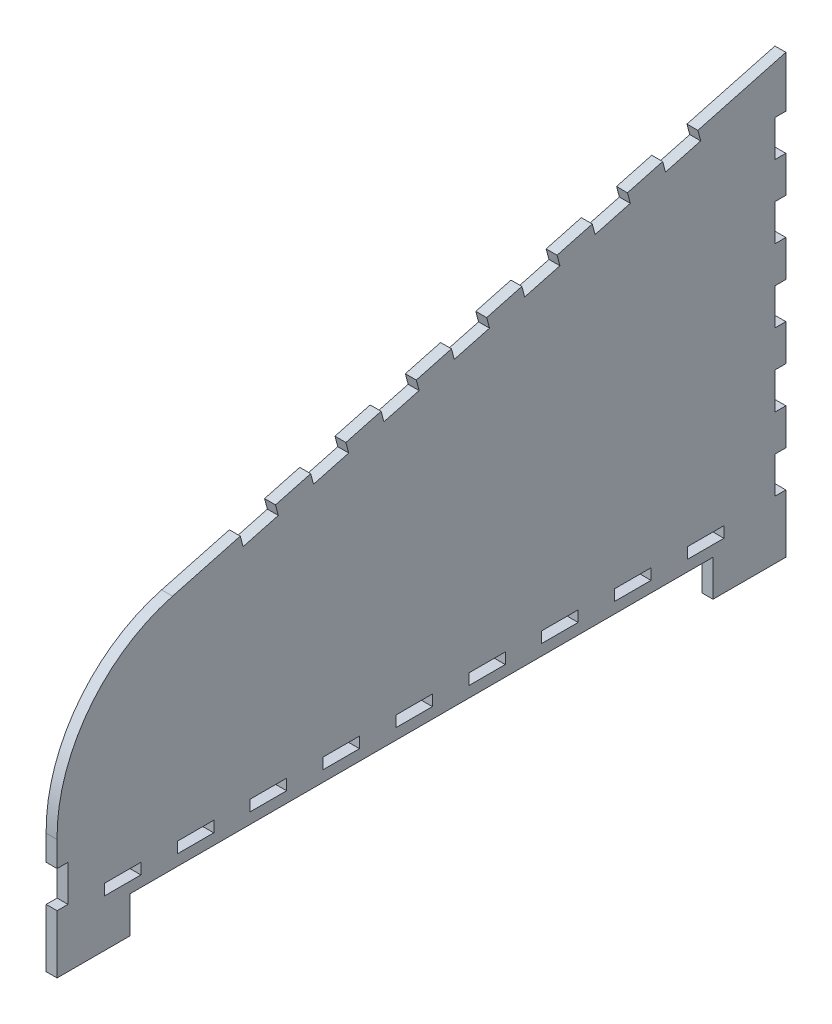
from build123d import *

# Parameters (mm, degrees)
SKETCH1_W           = 10
SKETCH1_H           = 3
BOSS_EXTRUDE1_DEPTH = 3


with BuildPart() as part:
    # Sketch1 → Boss-Extrude1 (new body)
    with BuildSketch(Plane(origin=(0, 0, 0), x_dir=(0, 0, -1), z_dir=(1, 0, 0))):
        with BuildLine():
            Line((-100, -44), (-100, -60))
            Line((-100, -60), (-80, -60))
            Line((-80, -60), (-80, -50))
            Line((-80, -50), (80, -50))
            Line((80, -50), (80, -60))
            Line((80, -60), (100, -60))
            Line((100, -60), (100, -44))
            Line((100, -44), (97, -44))
            Line((97, -44), (97, -34))
            Line((97, -34), (100, -34))
            Line((100, -34), (100, -24))
            Line((100, -24), (97, -24))
            Line((97, -24), (97, -14))
            Line((97, -14), (100, -14))
            Line((100, -14), (100, -4))
            Line((100, -4), (97, -4))
            Line((97, -4), (97, 6))
            Line((97, 6), (100, 6))
            Line((100, 6), (100, 16))
            Line((100, 16), (97, 16))
            Line((97, 16), (97, 26))
            Line((97, 26), (100, 26))
            Line((100, 26), (100, 36))
            Line((100, 36), (97, 36))
            Line((97, 36), (97, 46))
            Line((97, 46), (100, 46))
            Line((100, 46), (100, 60))
            Line((100, 60), (75.851854343, 53.529523872))
            Line((75.851854343, 53.529523872), (76.628311478, 50.631746394))
            Line((76.628311478, 50.631746394), (66.969053215, 48.043555943))
            Line((66.969053215, 48.043555943), (66.19259608, 50.941333421))
            Line((66.19259608, 50.941333421), (56.533337817, 48.35314297))
            Line((56.533337817, 48.35314297), (57.309794952, 45.455365492))
            Line((57.309794952, 45.455365492), (47.650536689, 42.86717504))
            Line((47.650536689, 42.86717504), (46.874079554, 45.764952519))
            Line((46.874079554, 45.764952519), (37.214821291, 43.176762068))
            Line((37.214821291, 43.176762068), (37.991278427, 40.278984589))
            Line((37.991278427, 40.278984589), (28.332020164, 37.690794138))
            Line((28.332020164, 37.690794138), (27.555563028, 40.588571617))
            Line((27.555563028, 40.588571617), (17.896304765, 38.000381166))
            Line((17.896304765, 38.000381166), (18.672761901, 35.102603687))
            Line((18.672761901, 35.102603687), (9.013503638, 32.514413236))
            Line((9.013503638, 32.514413236), (8.237046503, 35.412190715))
            Line((8.237046503, 35.412190715), (-1.42221176, 32.824000264))
            Line((-1.42221176, 32.824000264), (-0.645754625, 29.926222785))
            Line((-0.645754625, 29.926222785), (-10.305012888, 27.338032334))
            Line((-10.305012888, 27.338032334), (-11.081470023, 30.235809813))
            Line((-11.081470023, 30.235809813), (-20.740728286, 27.647619362))
            Line((-20.740728286, 27.647619362), (-19.964271151, 24.749841883))
            Line((-19.964271151, 24.749841883), (-29.623529414, 22.161651432))
            Line((-29.623529414, 22.161651432), (-30.399986549, 25.059428911))
            Line((-30.399986549, 25.059428911), (-40.059244812, 22.47123846))
            Line((-40.059244812, 22.47123846), (-39.282787677, 19.573460981))
            Line((-39.282787677, 19.573460981), (-48.942045939, 16.98527053))
            Line((-48.942045939, 16.98527053), (-49.718503075, 19.883048009))
            Line((-49.718503075, 19.883048009), (-68.302221487, 14.903555668))
            ThreePointArc((-68.302221487, 14.903555668), (-91.366544651, -0.636913735), (-100, -27.074247963))
            Line((-100, -27.074247963), (-100, -34))
            Line((-100, -34), (-97, -34))
            Line((-97, -34), (-97, -44))
            Line((-97, -44), (-100, -44))
        make_face()
        with Locations((-82, -45.5)):
            Rectangle(SKETCH1_W, SKETCH1_H, mode=Mode.SUBTRACT)
        with Locations((-62, -45.5)):
            Rectangle(SKETCH1_W, SKETCH1_H, mode=Mode.SUBTRACT)
        with Locations((-42, -45.5)):
            Rectangle(SKETCH1_W, SKETCH1_H, mode=Mode.SUBTRACT)
        with Locations((-22, -45.5)):
            Rectangle(SKETCH1_W, SKETCH1_H, mode=Mode.SUBTRACT)
        with Locations((-2, -45.5)):
            Rectangle(SKETCH1_W, SKETCH1_H, mode=Mode.SUBTRACT)
        with Locations((18, -45.5)):
            Rectangle(SKETCH1_W, SKETCH1_H, mode=Mode.SUBTRACT)
        with Locations((38, -45.5)):
            Rectangle(SKETCH1_W, SKETCH1_H, mode=Mode.SUBTRACT)
        with Locations((58, -45.5)):
            Rectangle(SKETCH1_W, SKETCH1_H, mode=Mode.SUBTRACT)
        with Locations((78, -45.5)):
            Rectangle(SKETCH1_W, SKETCH1_H, mode=Mode.SUBTRACT)
    extrude(amount=BOSS_EXTRUDE1_DEPTH)


solid = part.part
